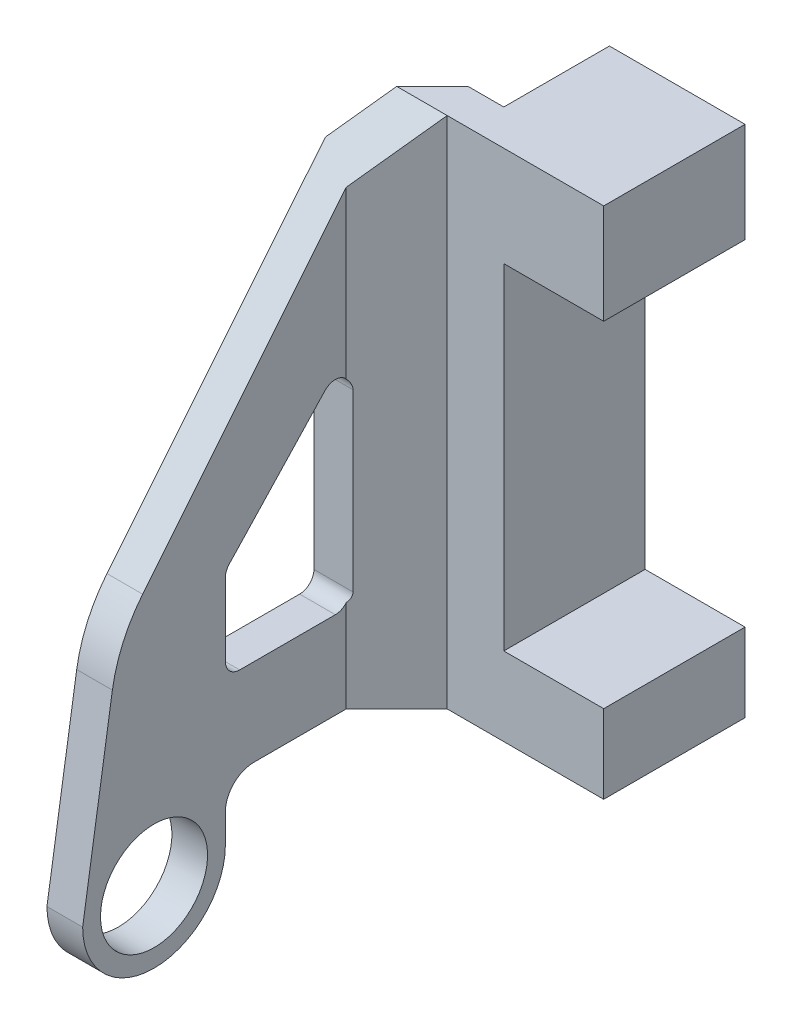
from build123d import *

# Parameters (mm, degrees)
SZKIC1_W                    = 9.5
SZKIC1_H                    = 36
DODANIE_WYCI_GNI_CIE1_DEPTH = 9.9
SZKIC2_W                    = 7
SZKIC2_H                    = 23.5
WYTNIJ_WYCI_GNI_CIE1_DEPTH  = 9.9
SZKIC3_R                    = 2.5
DODANIE_WYCI_GNI_CIE2_DEPTH = 7.5
WYTNIJ_WYCI_GNI_CIE2_DEPTH  = 137.5
WYTNIJ_WYCI_GNI_CIE3_DEPTH  = 137.5
ZAOKR_GLENIE1_R             = 10
ZAOKR_GLENIE2_R             = 2
SZKIC6_R                    = 3.75
WYTNIJ_WYCI_GNI_CIE4_DEPTH  = 10


with BuildPart() as part:
    # Szkic1 → Dodanie-wyciągnięcie1 (new body)
    with BuildSketch(Plane.XY):
        with Locations((-4.75, 18)):
            Rectangle(SZKIC1_W, SZKIC1_H)
    extrude(amount=DODANIE_WYCI_GNI_CIE1_DEPTH)

    # Szkic2 → Wytnij-wyciągnięcie1 (cut)
    with BuildSketch(Plane.XY.offset(9.9)):
        with Locations((-3.5, 17.25)):
            Rectangle(SZKIC2_W, SZKIC2_H)
    extrude(amount=-WYTNIJ_WYCI_GNI_CIE1_DEPTH, mode=Mode.SUBTRACT)

    # Szkic3 → Dodanie-wyciągnięcie2 (add)
    with BuildSketch(Plane.ZY.offset(9.5)):
        with BuildLine():
            Line((7.4, 36), (9.9, 36))
            Line((9.9, 36), (12.4, 32.923076923))
            Line((12.4, 32.923076923), (29.4, 12))
            Line((29.4, 12), (31.9, -4))
            ThreePointArc((31.9, -4), (26.9, -9), (21.9, -4))
            Line((21.9, -4), (21.9, 0))
            Line((21.9, 0), (12.4, 0))
            Line((12.4, 0), (7.4, 0))
            Line((7.4, 0), (7.4, 36))
        make_face()
        with Locations((26.9, -4)):
            Circle(SZKIC3_R, mode=Mode.SUBTRACT)
    extrude(amount=DODANIE_WYCI_GNI_CIE2_DEPTH)

    # Szkic4 → Wytnij-wyciągnięcie2 (cut)
    with BuildSketch(Plane(origin=(0, 36, 0), x_dir=(1, 0, 0), z_dir=(0, 1, 0))):
        Polygon((-12, -7.4), (-22.251097051, -17.651097051), (-26.525986736, -7.4), align=None)
        Polygon((-10.964466094, -9.9), (-14.5, -13.435533906), (-14.5, -34.97095788), (-2.856589665, -34.97095788), (-4.384348652, -9.9), align=None)
    extrude(amount=-WYTNIJ_WYCI_GNI_CIE2_DEPTH, mode=Mode.SUBTRACT)

    # Szkic5 → Wytnij-wyciągnięcie3 (cut)
    with BuildSketch(Plane.ZY.offset(17)):
        with BuildLine():
            Line((14.930271414, 20.050399523), (21.630271414, 12.888330558))
            ThreePointArc((21.630271414, 12.888330558), (21.830126715, 12.572412171), (21.9, 12.205173429))
            Line((21.9, 12.205173429), (21.9, 7.1))
            ThreePointArc((21.9, 7.1), (21.607106781, 6.392893219), (20.9, 6.1))
            Line((20.9, 6.1), (14.2, 6.1))
            ThreePointArc((14.2, 6.1), (13.492893219, 6.392893219), (13.2, 7.1))
            Line((13.2, 7.1), (13.2, 19.367242395))
            ThreePointArc((13.2, 19.367242395), (13.832761259, 20.29736911), (14.930271414, 20.050399523))
        make_face()
    extrude(amount=-WYTNIJ_WYCI_GNI_CIE3_DEPTH, mode=Mode.SUBTRACT)

    # Zaokrąglenie1
    zaokr_glenie1_edges = [part.edges().sort_by_distance(p)[0] for p in [
        (-15.75, 12, 29.4),
    ]]
    fillet(zaokr_glenie1_edges, radius=ZAOKR_GLENIE1_R)

    # Zaokrąglenie2
    zaokr_glenie2_edges = [part.edges().sort_by_distance(p)[0] for p in [
        (-15.75, 0, 21.9),
    ]]
    fillet(zaokr_glenie2_edges, radius=ZAOKR_GLENIE2_R)

    # Szkic6 → Wytnij-wyciągnięcie4 (cut)
    with BuildSketch(Plane.ZY.offset(17)):
        with Locations((26.9, -4)):
            Circle(SZKIC6_R)
    extrude(amount=-WYTNIJ_WYCI_GNI_CIE4_DEPTH, mode=Mode.SUBTRACT)


solid = part.part
